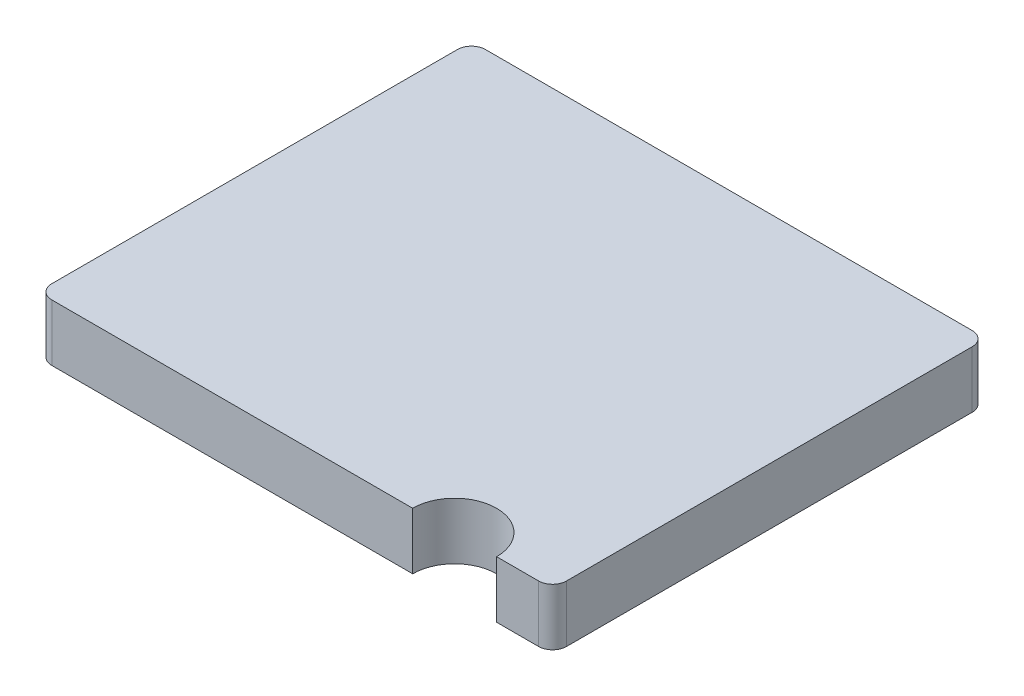
from build123d import *

# Parameters (mm, degrees)
SKETCH1_W           = 1.84
SKETCH1_H           = 1.55
BOSS_EXTRUDE1_DEPTH = 0.203
FILLET1_R           = 0.05
SKETCH2_R           = 0.15
CUT_EXTRUDE1_DEPTH  = 1.203


with BuildPart() as part:
    # Sketch1 → Boss-Extrude1 (new body)
    with BuildSketch(Plane(origin=(0, 0, 0), x_dir=(1, 0, 0), z_dir=(0, 1, 0))):
        Rectangle(SKETCH1_W, SKETCH1_H)
    extrude(amount=BOSS_EXTRUDE1_DEPTH)

    # Fillet1
    fillet1_edges = [part.edges().sort_by_distance(p)[0] for p in [
        (0.92, 0.1015, 0.775),
        (-0.92, 0.1015, 0.775),
        (-0.92, 0.1015, -0.775),
        (0.92, 0.1015, -0.775),
    ]]
    fillet(fillet1_edges, radius=FILLET1_R)

    # Sketch2 → Cut-Extrude1 (cut, through all)
    with BuildSketch(Plane(origin=(0, 0.203, 0), x_dir=(1, 0, 0), z_dir=(0, 1, 0))):
        with Locations((0.57, -0.775)):
            Circle(SKETCH2_R)
    extrude(amount=-CUT_EXTRUDE1_DEPTH, mode=Mode.SUBTRACT)


solid = part.part
